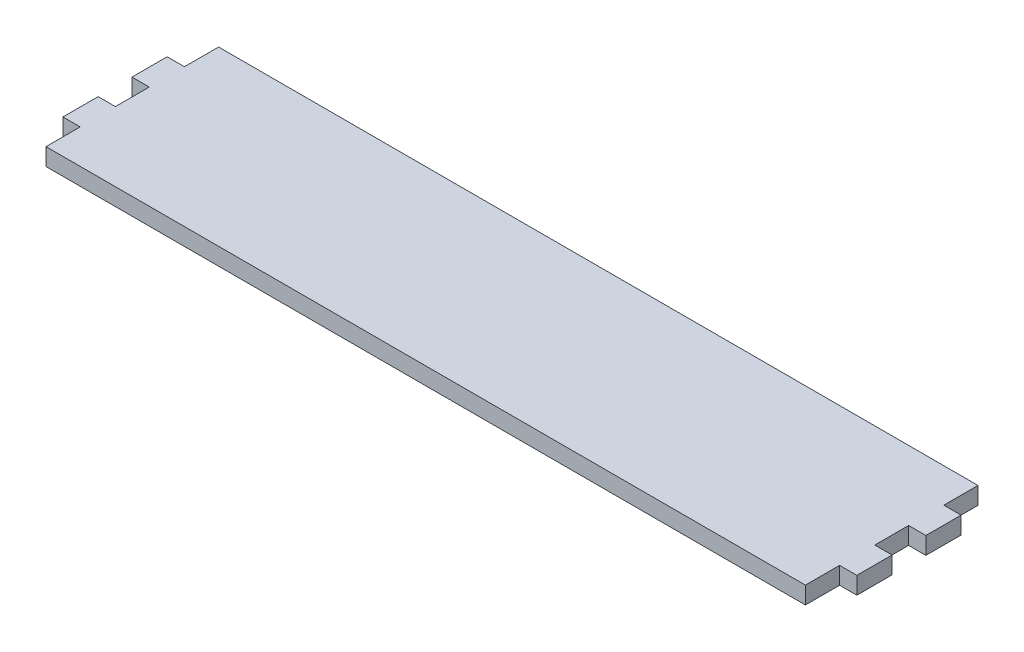
from build123d import *

# Parameters (mm, degrees)
BOSS_EXTRUDE1_DEPTH = 6.35


with BuildPart() as part:
    # Sketch1 → Boss-Extrude1 (new body)
    with BuildSketch(Plane(origin=(0, 0, 0), x_dir=(1, 0, 0), z_dir=(0, 1, 0))):
        Polygon((0, 0), (279.4, 0), (279.4, -12.573), (285.75, -12.573), (285.75, -25.527), (279.4, -25.527), (279.4, -37.973), (285.75, -37.973), (285.75, -50.927), (279.4, -50.927), (279.4, -63.5), (0, -63.5), (0, -50.927), (-6.35, -50.927), (-6.35, -37.973), (0, -37.973), (0, -25.527), (-6.35, -25.527), (-6.35, -12.573), (0, -12.573), align=None)
    extrude(amount=BOSS_EXTRUDE1_DEPTH)


solid = part.part
